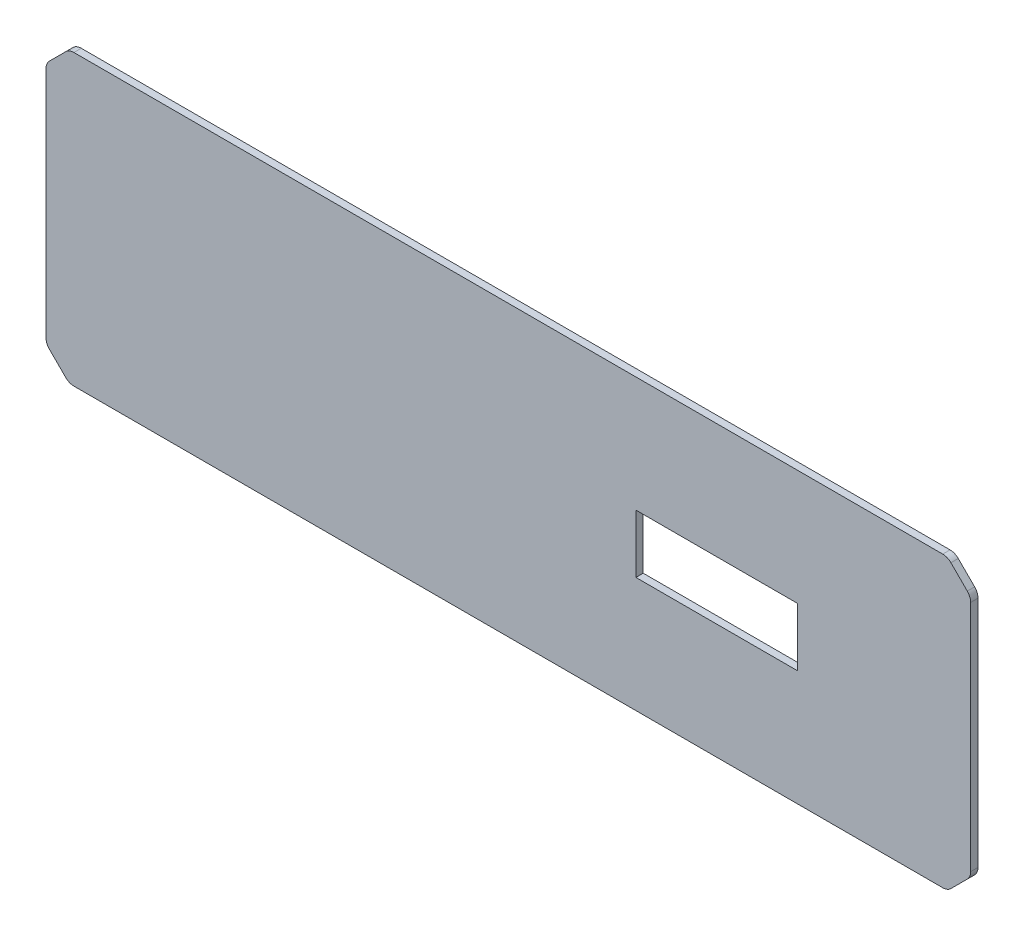
from build123d import *

# Parameters (mm, degrees)
SKETCH1_W           = 400
SKETCH1_H           = 125
BOSS_EXTRUDE1_DEPTH = 3.175
SKETCH2_W           = 69.83
SKETCH2_H           = 25.23
CUT_EXTRUDE1_DEPTH  = 3.175
CHAMFER1_SIZE       = 10
FILLET1_R           = 5


with BuildPart() as part:
    # Sketch1 → Boss-Extrude1 (new body)
    with BuildSketch(Plane.XY):
        Rectangle(SKETCH1_W, SKETCH1_H)
    extrude(amount=BOSS_EXTRUDE1_DEPTH)

    # Sketch2 → Cut-Extrude1 (cut)
    with BuildSketch(Plane.XY.offset(3.175)):
        with Locations((90.085, 0)):
            Rectangle(SKETCH2_W, SKETCH2_H)
    extrude(amount=-CUT_EXTRUDE1_DEPTH, mode=Mode.SUBTRACT)

    # Chamfer1
    chamfer1_edges = [part.edges().sort_by_distance(p)[0] for p in [
        (200, -62.5, 1.5875),
        (-200, -62.5, 1.5875),
        (-200, 62.5, 1.5875),
        (200, 62.5, 1.5875),
    ]]
    chamfer(chamfer1_edges, length=CHAMFER1_SIZE)

    # Fillet1
    fillet1_edges = [part.edges().sort_by_distance(p)[0] for p in [
        (200, 52.5, 1.5875),
        (200, -52.5, 1.5875),
        (-190, -62.5, 1.5875),
        (190, -62.5, 1.5875),
        (-190, 62.5, 1.5875),
        (190, 62.5, 1.5875),
        (-200, -52.5, 1.5875),
        (-200, 52.5, 1.5875),
    ]]
    fillet(fillet1_edges, radius=FILLET1_R)


solid = part.part
